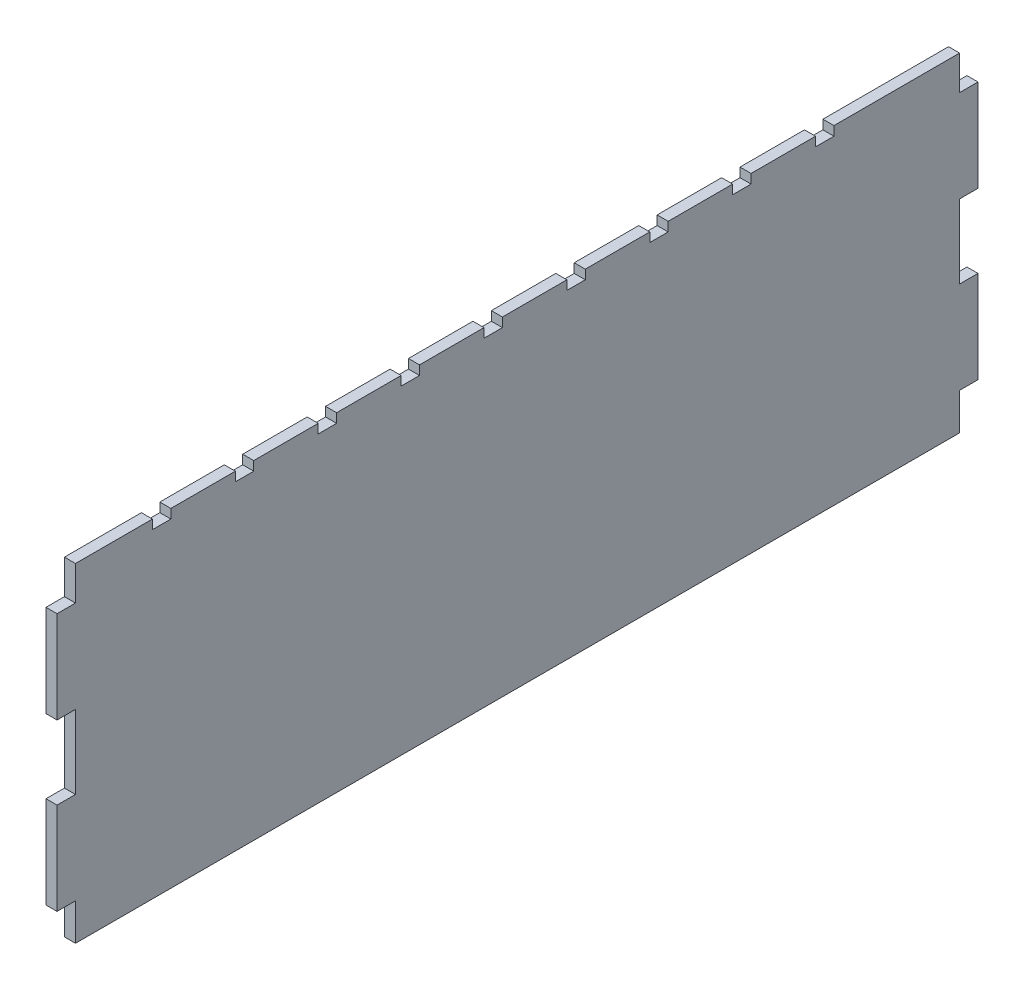
from build123d import *

# Parameters (mm, degrees)
EXTRUDE_2_DEPTH = 6


with BuildPart() as part:
    # Эскиз1 → Бобышка-Вытянуть2 (new body)
    with BuildSketch(Plane(origin=(0, 0, 0), x_dir=(0, 0, -1), z_dir=(1, 0, 0))):
        Polygon((240, -90), (-240, -90), (-240, -70), (-250, -70), (-250, -20), (-240, -20), (-240, 20), (-250, 20), (-250, 70), (-240, 70), (-240, 88.6), (-198.210576245, 88.6), (-198.210576245, 83.6), (-188.210576245, 83.6), (-188.210576245, 88.6), (-153.210576245, 88.6), (-153.210576245, 83.6), (-143.210576245, 83.6), (-143.210576245, 88.6), (-108.210576245, 88.6), (-108.210576245, 83.6), (-98.210576245, 83.6), (-98.210576245, 88.6), (-63.210576245, 88.6), (-63.210576245, 83.6), (-53.210576245, 83.6), (-53.210576245, 88.6), (-18.210576245, 88.6), (-18.210576245, 83.6), (-8.210576245, 83.6), (-8.210576245, 88.6), (26.789423755, 88.6), (26.789423755, 83.6), (36.789423755, 83.6), (36.789423755, 88.6), (71.789423755, 88.6), (71.789423755, 83.6), (81.789423755, 83.6), (81.789423755, 88.6), (116.789423755, 88.6), (116.789423755, 83.6), (126.789423755, 83.6), (126.789423755, 88.6), (161.789423755, 88.6), (161.789423755, 83.6), (171.789423755, 83.6), (171.789423755, 88.6), (240, 88.6), (240, 70), (250, 70), (250, 20), (240, 20), (240, -20), (250, -20), (250, -70), (240, -70), align=None)
    extrude(amount=EXTRUDE_2_DEPTH)


solid = part.part
